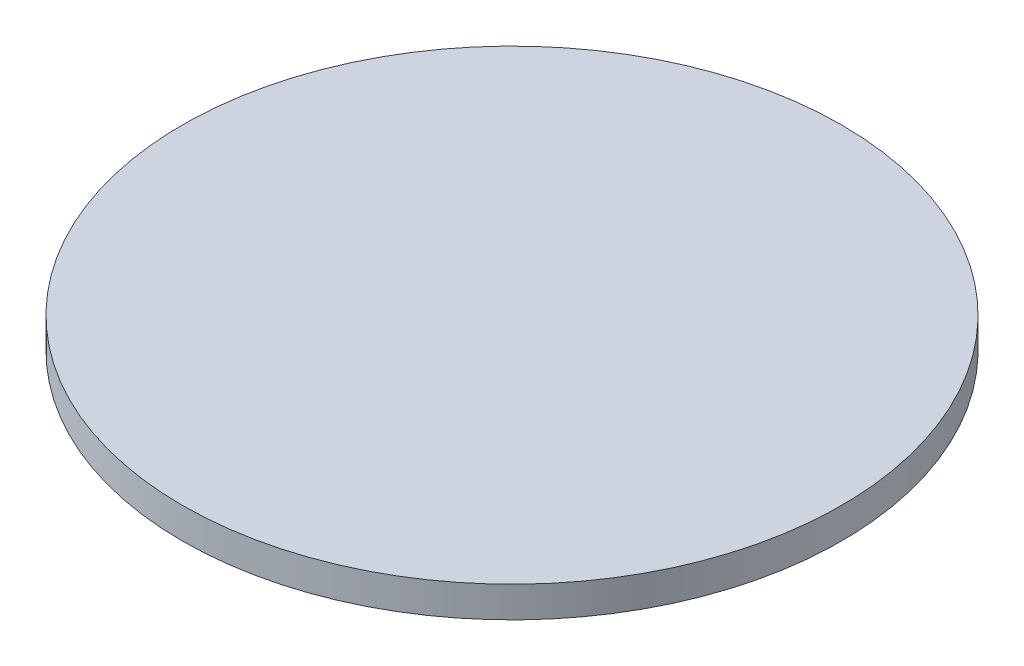
from build123d import *

# Parameters (mm, degrees)
SKETCH1_R           = 32
BOSS_EXTRUDE1_DEPTH = 3


with BuildPart() as part:
    # Sketch1 → Boss-Extrude1 (new body)
    with BuildSketch(Plane(origin=(0, 0, 0), x_dir=(1, 0, 0), z_dir=(0, 1, 0))):
        with Locations((8.815546452, 5.829461803)):
            Circle(SKETCH1_R)
    extrude(amount=BOSS_EXTRUDE1_DEPTH)


solid = part.part
